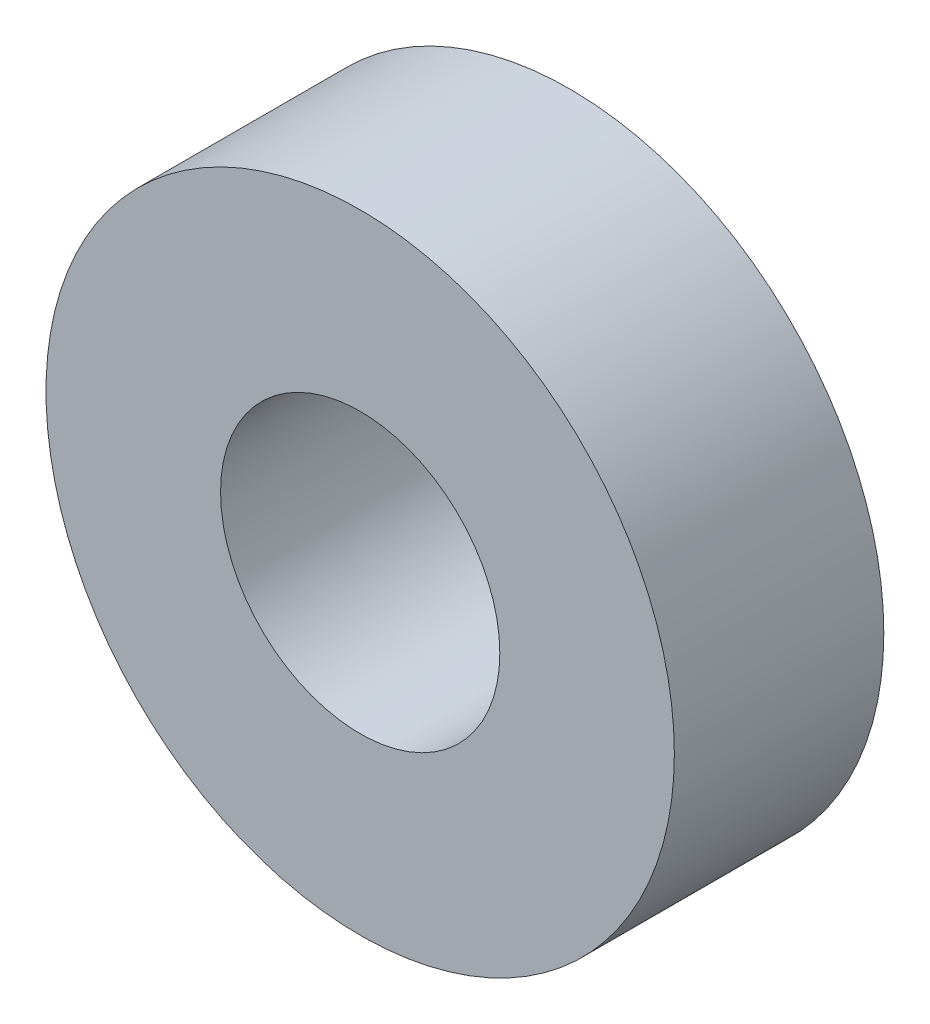
from build123d import *

# Parameters (mm, degrees)
SKETCH1_R           = 2.25
SKETCH1_R_2         = 1
BOSS_EXTRUDE1_DEPTH = 1.5


with BuildPart() as part:
    # Sketch1 → Boss-Extrude1 (new body)
    with BuildSketch(Plane.XY):
        Circle(SKETCH1_R)
        Circle(SKETCH1_R_2, mode=Mode.SUBTRACT)
    extrude(amount=BOSS_EXTRUDE1_DEPTH)


solid = part.part
